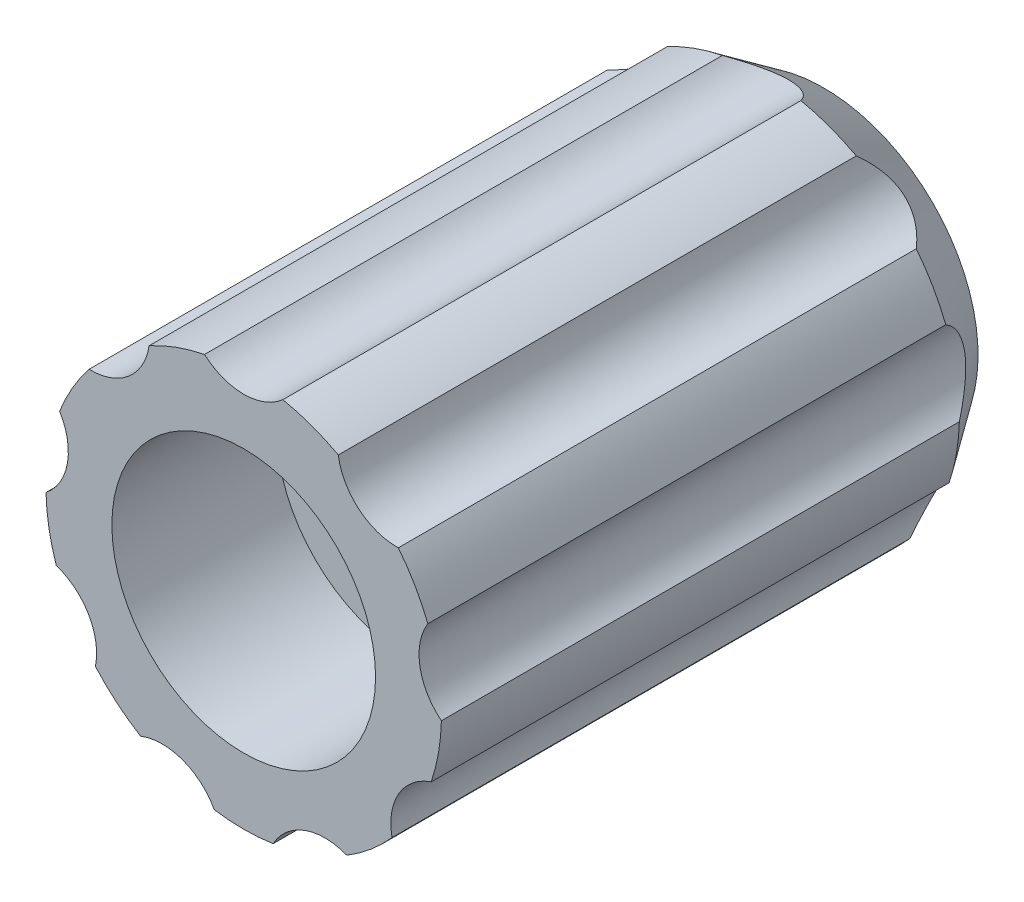
from build123d import *

# Parameters (mm, degrees)
SKICA1_R                 = 6
P_IDAT_VYSUNUT_M1_DEPTH  = 7
SKICA5_R                 = 6
SKICA5_R_2               = 4
P_IDAT_VYSUNUT_M3_DEPTH  = 5
SKICA6_R                 = 6
P_IDAT_VYSUNUT_M4_DEPTH  = 0.6
SKICA7_R                 = 1.266795128
P_IDAT_VYSUNUT_M5_DEPTH  = 1
SKICA8_R                 = 1.792460028
ODEBRAT_VYSUNUT_M2_DEPTH = 21
ODEBRAT_VYSUNUT_M4_DEPTH = 7
P_IDAT_VYSUNUT_M6_DEPTH  = 0.5
P_IDAT_VYSUNUT_M7_DEPTH  = 5


with BuildPart() as part:
    # Skica1 → Přidat vysunutím1 (new body)
    with BuildSketch(Plane.XY):
        Circle(SKICA1_R)
        with BuildLine():
            Line((-2.524876235, -1.575), (2.524876235, -1.575))
            ThreePointArc((2.524876235, -1.575), (2.627027018, -1.546945391), (2.700519799, -1.470652174))
            ThreePointArc((2.700519799, -1.470652174), (0, 3.075), (-2.700519799, -1.470652174))
            ThreePointArc((-2.700519799, -1.470652174), (-2.627027018, -1.546945391), (-2.524876235, -1.575))
        make_face(mode=Mode.SUBTRACT)
    extrude(amount=P_IDAT_VYSUNUT_M1_DEPTH)

    # Skica5 → Přidat vysunutím3 (add)
    with BuildSketch(Plane.XY.offset(7)):
        Circle(SKICA5_R)
        Circle(SKICA5_R_2, mode=Mode.SUBTRACT)
    extrude(amount=P_IDAT_VYSUNUT_M3_DEPTH)

    # Skica6 → Přidat vysunutím4 (add)
    with BuildSketch(Plane(origin=(0, 0, 0), x_dir=(-1, 0, 0), z_dir=(0, 0, -1))):
        Circle(SKICA6_R)
    extrude(amount=P_IDAT_VYSUNUT_M4_DEPTH)

    # Skica7 → Přidat vysunutím5 (add)
    with BuildSketch(Plane.XY.offset(5)):
        with Locations((0, -2.741795128)):
            Circle(SKICA7_R)
    extrude(amount=-P_IDAT_VYSUNUT_M5_DEPTH)

    # Skica8 → Odebrat vysunutím2 (cut)
    with BuildSketch(Plane.XY.offset(12)):
        with Locations((0, 7.222215072)):
            Circle(SKICA8_R)
        with Locations((4.642350363, 5.532537723)):
            Circle(SKICA8_R)
        with Locations((7.112493397, 1.254124486)):
            Circle(SKICA8_R)
        with Locations((6.254621724, -3.611107536)):
            Circle(SKICA8_R)
        with Locations((2.470143034, -6.786662209)):
            Circle(SKICA8_R)
        with Locations((-2.470143034, -6.786662209)):
            Circle(SKICA8_R)
        with Locations((-6.254621724, -3.611107536)):
            Circle(SKICA8_R)
        with Locations((-7.112493397, 1.254124486)):
            Circle(SKICA8_R)
        with Locations((-4.642350363, 5.532537723)):
            Circle(SKICA8_R)
    extrude(amount=-ODEBRAT_VYSUNUT_M2_DEPTH, mode=Mode.SUBTRACT)

    # Skica11 → Odebrat vysunutím4 (cut)
    with BuildSketch(Plane.XY.offset(7)):
        with BuildLine():
            Line((-2.524876235, -1.645), (2.524876235, -1.645))
            ThreePointArc((2.524876235, -1.645), (2.662779793, -1.607126277), (2.761995046, -1.504130435))
            ThreePointArc((2.761995046, -1.504130435), (0, 3.145), (-2.761995046, -1.504130435))
            ThreePointArc((-2.761995046, -1.504130435), (-2.662779793, -1.607126277), (-2.524876235, -1.645))
        make_face()
    extrude(amount=-ODEBRAT_VYSUNUT_M4_DEPTH, mode=Mode.SUBTRACT)

    # Skica12 → Přidat vysunutím6 (add, symmetric)
    with BuildSketch(Plane(origin=(0, 0, 0), x_dir=(0, 0, -1), z_dir=(1, 0, 0))):
        Polygon((-2, -1.645), (0, -1.495), (0, -1.645), align=None)
    extrude(amount=P_IDAT_VYSUNUT_M6_DEPTH, both=True)

    # Skica13 → Přidat vysunutím7 (add)
    with BuildSketch(Plane(origin=(0, 0, -0.6), x_dir=(-1, 0, 0), z_dir=(0, 0, -1))):
        with BuildLine():
            ThreePointArc((2.869302785, 5.269449832), (3.490179266, 4.159433679), (4.691145849, 3.740741989))
            ThreePointArc((4.691145849, 3.740741989), (5.196152423, 3), (5.585150516, 2.192280483))
            ThreePointArc((5.585150516, 2.192280483), (5.347264864, 0.942867069), (5.998128811, -0.149835813))
            ThreePointArc((5.998128811, -0.149835813), (5.908846518, -1.041889066), (5.687644248, -1.910681268))
            ThreePointArc((5.687644248, -1.910681268), (4.702305805, -2.714877522), (4.498520641, -3.970303773))
            ThreePointArc((4.498520641, -3.970303773), (3.856725658, -4.596266659), (3.128826026, -5.119614019))
            ThreePointArc((3.128826026, -5.119614019), (1.857085598, -5.102300748), (0.894004667, -5.933022472))
            ThreePointArc((0.894004667, -5.933022472), (0, -6), (-0.894004667, -5.933022472))
            ThreePointArc((-0.894004667, -5.933022472), (-1.857085598, -5.102300748), (-3.128826026, -5.119614019))
            ThreePointArc((-3.128826026, -5.119614019), (-3.856725658, -4.596266659), (-4.498520641, -3.970303773))
            ThreePointArc((-4.498520641, -3.970303773), (-4.702305805, -2.714877522), (-5.687644248, -1.910681268))
            ThreePointArc((-5.687644248, -1.910681268), (-5.908846518, -1.041889066), (-5.998128811, -0.149835813))
            ThreePointArc((-5.998128811, -0.149835813), (-5.347264864, 0.942867069), (-5.585150516, 2.192280483))
            ThreePointArc((-5.585150516, 2.192280483), (-5.196152423, 3), (-4.691145849, 3.740741989))
            ThreePointArc((-4.691145849, 3.740741989), (-3.490179266, 4.159433679), (-2.869302785, 5.269449832))
            ThreePointArc((-2.869302785, 5.269449832), (-2.05212086, 5.638155725), (-1.189123608, 5.88098504))
            ThreePointArc((-1.189123608, 5.88098504), (0, 5.429755044), (1.189123608, 5.88098504))
            ThreePointArc((1.189123608, 5.88098504), (2.05212086, 5.638155725), (2.869302785, 5.269449832))
        make_face()
    extrude(amount=P_IDAT_VYSUNUT_M7_DEPTH)

    # Skica14 → Odebrat rotací1 (revolve, cut)
    with BuildSketch(Plane(origin=(0, 0, 0), x_dir=(1, 0, 0), z_dir=(0, 1, 0))):
        Polygon((-0.519399501, 11.540173112), (-8.873937642, -0.391343881), (-8.306128357, 8.726101498), align=None)
    revolve(axis=Axis((0, 0, 0), (0, 0, -1)), mode=Mode.SUBTRACT)


solid = part.part
